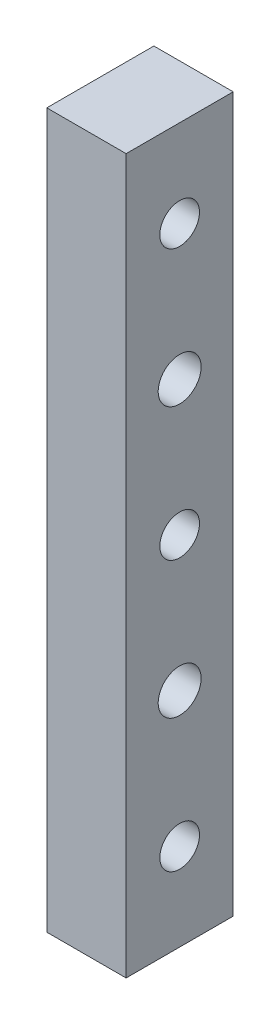
from build123d import *

# Parameters (mm, degrees)
SKETCH1_W                    = 13.5
SKETCH1_H                    = 90
BOSS_EXTRUDE1_DEPTH          = 10
F_1_4_28_TAPPED_HOLE1_D      = 5.4102
F_5_0_5_DIAMETER_HOLE1_D     = 5
F_5_0_5_DIAMETER_HOLE1_DEPTH = 49.5
F_5_0_5_DIAMETER_HOLE1_TIP   = 1.502151548
CUT_EXTRUDE2_DEPTH           = 5


with BuildPart() as part:
    # Sketch1 → Boss-Extrude1 (new body)
    with BuildSketch(Plane(origin=(0, 0, 0), x_dir=(0, 0, -1), z_dir=(1, 0, 0))):
        with Locations((1.965094474, 8.62782)):
            Rectangle(SKETCH1_W, SKETCH1_H)
    extrude(amount=BOSS_EXTRUDE1_DEPTH)

    # 1/4-28 Tapped Hole1 (through all)
    with Locations(Plane(origin=(10, 0, 0), x_dir=(0, 0, -1), z_dir=(1, 0, 0))):
        with Locations((1.965094474, 25.62782), (1.965094474, -8.37218)):
            Hole(F_1_4_28_TAPPED_HOLE1_D / 2)

    # Ø5.0 (5) Diameter Hole1
    with Locations(Plane(origin=(10, 0, 0), x_dir=(0, 0, -1), z_dir=(1, 0, 0))):
        with Locations((1.965094474, 42.62782), (1.965094474, -25.37218), (1.965094474, 8.62782)):
            Hole(F_5_0_5_DIAMETER_HOLE1_D / 2, depth=F_5_0_5_DIAMETER_HOLE1_DEPTH)
            with Locations((0, 0, -(F_5_0_5_DIAMETER_HOLE1_DEPTH + F_5_0_5_DIAMETER_HOLE1_TIP / 2))):  # 118° drill point
                Cone(0, F_5_0_5_DIAMETER_HOLE1_D / 2, F_5_0_5_DIAMETER_HOLE1_TIP, mode=Mode.SUBTRACT)

    # Sketch7 → Cut-Extrude2 (cut)
    with BuildSketch(Plane.ZY):
        Polygon((2.009905526, 40.33285268), (2.009905526, 44.92278732), (-1.965094474, 47.21775464), (-5.940094474, 44.92278732), (-5.940094474, 40.33285268), (-1.965094474, 38.03788536), align=None)
        Polygon((2.009905526, 6.33285268), (2.009905526, 10.92278732), (-1.965094474, 13.21775464), (-5.940094474, 10.92278732), (-5.940094474, 6.33285268), (-1.965094474, 4.03788536), align=None)
        Polygon((2.009905526, -27.66714732), (2.009905526, -23.07721268), (-1.965094474, -20.78224536), (-5.940094474, -23.07721268), (-5.940094474, -27.66714732), (-1.965094474, -29.96211464), align=None)
    extrude(amount=-CUT_EXTRUDE2_DEPTH, mode=Mode.SUBTRACT)


solid = part.part
